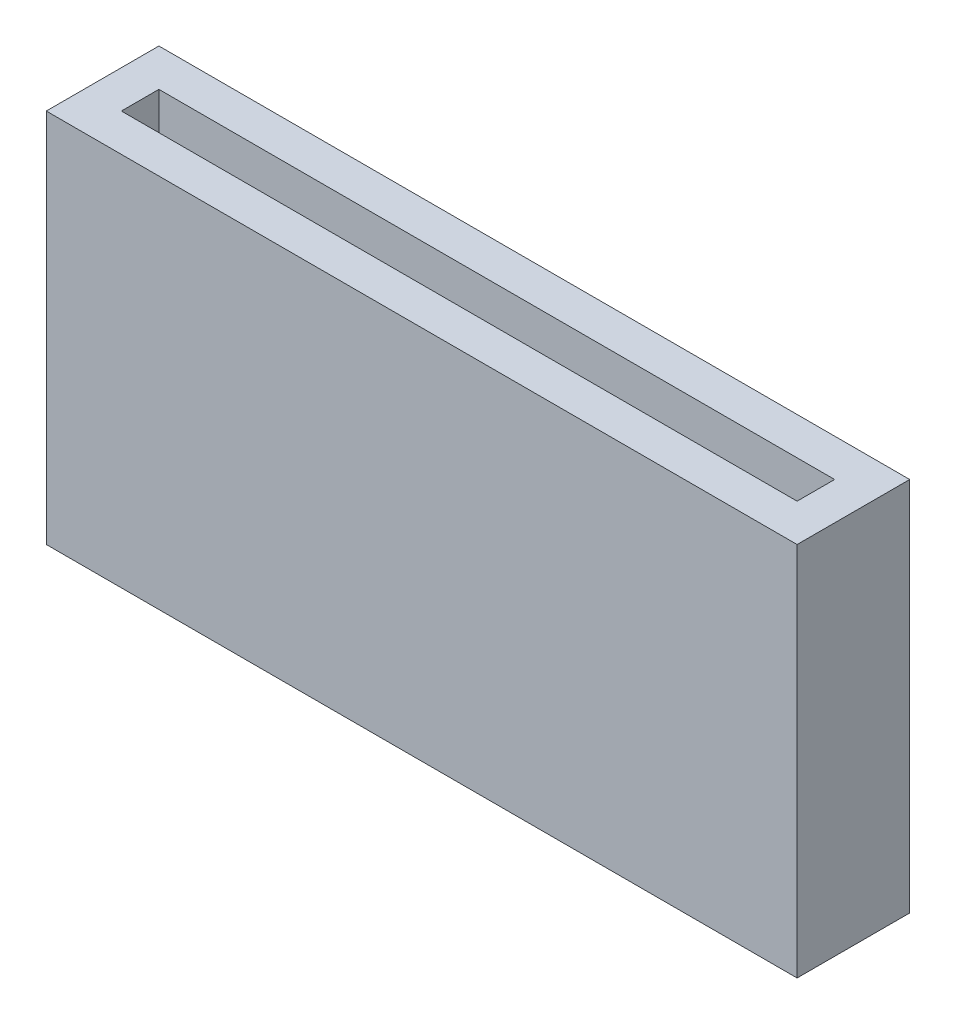
from build123d import *

# Parameters (mm, degrees)
SKETCH2_W           = 8
SKETCH2_H           = 4
BOSS_EXTRUDE1_DEPTH = 0.4
SKETCH3_W           = 0.4
SKETCH3_H           = 4
BOSS_EXTRUDE2_DEPTH = 0.8
SKETCH4_W           = 0.4
SKETCH4_H           = 4
BOSS_EXTRUDE3_DEPTH = 0.8
BOSS_EXTRUDE4_REACH = 9.6
SKETCH5_W           = 0.4
SKETCH5_H           = 4


with BuildPart() as part:
    # Sketch2 → Boss-Extrude1 (new body)
    with BuildSketch(Plane.XY):
        Rectangle(SKETCH2_W, SKETCH2_H)
    extrude(amount=BOSS_EXTRUDE1_DEPTH)

    # Sketch3 → Boss-Extrude2 (add)
    with BuildSketch(Plane.XY.offset(0.4)):
        with Locations((-3.8, 0)):
            Rectangle(SKETCH3_W, SKETCH3_H)
    extrude(amount=BOSS_EXTRUDE2_DEPTH)

    # Sketch4 → Boss-Extrude3 (add)
    with BuildSketch(Plane.XY.offset(0.4)):
        with Locations((3.8, 0)):
            Rectangle(SKETCH4_W, SKETCH4_H)
    extrude(amount=BOSS_EXTRUDE3_DEPTH)

    # Sketch5 → Boss-Extrude4 (add, up to next)
    with BuildSketch(Plane(origin=(-3.6, 0, 0), x_dir=(0, 0, -1), z_dir=(1, 0, 0)), mode=Mode.PRIVATE) as boss_extrude4_sk1:
        with Locations((-1, 0)):
            Rectangle(SKETCH5_W, SKETCH5_H)
    boss_extrude4_tool1 = extrude(boss_extrude4_sk1.sketch, amount=BOSS_EXTRUDE4_REACH, mode=Mode.PRIVATE) - part.part
    add(boss_extrude4_tool1.solids().sort_by_distance((-3.6, 0, 1))[0])


solid = part.part
